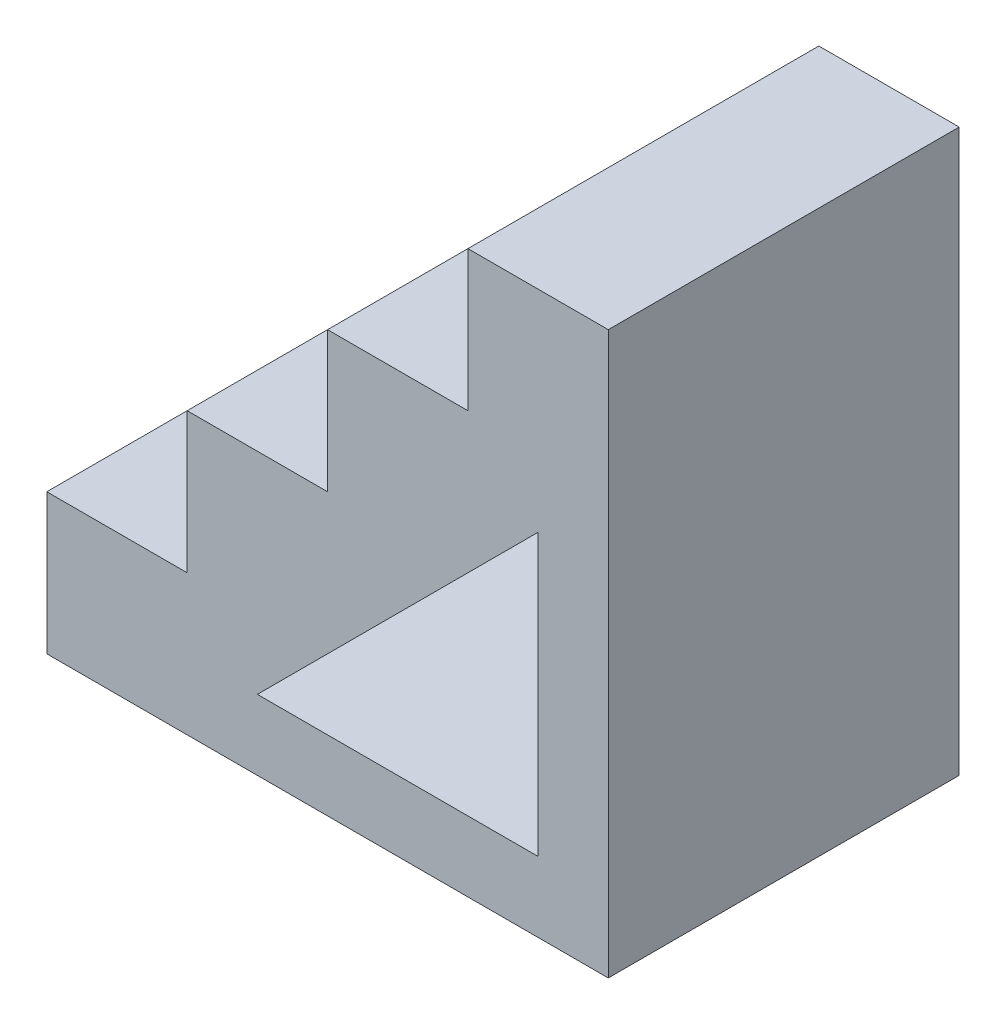
from build123d import *

# Parameters (mm, degrees)
BOSS_EXTRUDE1_DEPTH = 50
CUT_EXTRUDE1_DEPTH  = 51


with BuildPart() as part:
    # Sketch1 → Boss-Extrude1 (new body)
    with BuildSketch(Plane.XY):
        Polygon((0, 0), (0, 20), (20, 20), (20, 40), (40, 40), (40, 60), (60, 60), (60, 80), (80, 80), (80, 0), align=None)
    extrude(amount=BOSS_EXTRUDE1_DEPTH)

    # Sketch2 → Cut-Extrude1 (cut, through all)
    with BuildSketch(Plane.XY.offset(50)):
        Polygon((70, 50), (70, 10), (30, 10), align=None)
    extrude(amount=-CUT_EXTRUDE1_DEPTH, mode=Mode.SUBTRACT)


solid = part.part
